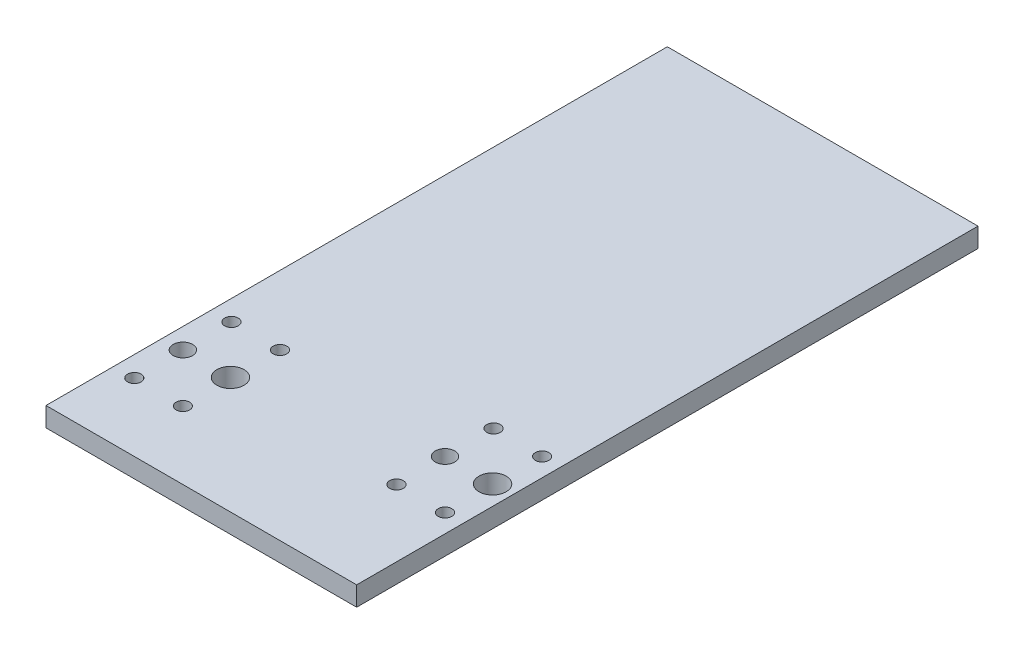
from build123d import *

# Parameters (mm, degrees)
SKETCH_1_W          = 16
SKETCH_1_H          = 32
EXTRUDE_1_DEPTH     = 1
SKETCH_2_R          = 0.7
SKETCH_2_R_2        = 0.5
SKETCH_2_R_3        = 0.35
CUT_EXTRUDE_1_DEPTH = 2


with BuildPart() as part:
    # Эскиз1 → Бобышка-Вытянуть1 (new body)
    with BuildSketch(Plane(origin=(0, 0, 0), x_dir=(1, 0, 0), z_dir=(0, 1, 0))):
        with Locations((8, 18.609346151)):
            Rectangle(SKETCH_1_W, SKETCH_1_H)
    extrude(amount=EXTRUDE_1_DEPTH)

    # Эскиз2 → Вырез-Вытянуть1 (cut, through all)
    with BuildSketch(Plane(origin=(0, 1, 0), x_dir=(1, 0, 0), z_dir=(0, 1, 0))):
        with Locations((15, 10.609346151)):
            Circle(SKETCH_2_R)
        with Locations((12.55, 10.609346151)):
            Circle(SKETCH_2_R_2)
        with Locations((3.5, 8.609346151)):
            Circle(SKETCH_2_R)
        with Locations((1.05, 8.609346151)):
            Circle(SKETCH_2_R_2)
        with Locations((12.55, 13.109346151)):
            Circle(SKETCH_2_R_3)
        with Locations((15.05, 13.109346151)):
            Circle(SKETCH_2_R_3)
        with Locations((15.05, 8.109346151)):
            Circle(SKETCH_2_R_3)
        with Locations((12.55, 8.109346151)):
            Circle(SKETCH_2_R_3)
        with Locations((3.55, 11.109346151)):
            Circle(SKETCH_2_R_3)
        with Locations((1.05, 11.109346151)):
            Circle(SKETCH_2_R_3)
        with Locations((1.05, 6.109346151)):
            Circle(SKETCH_2_R_3)
        with Locations((3.55, 6.109346151)):
            Circle(SKETCH_2_R_3)
    extrude(amount=-CUT_EXTRUDE_1_DEPTH, mode=Mode.SUBTRACT)


solid = part.part
